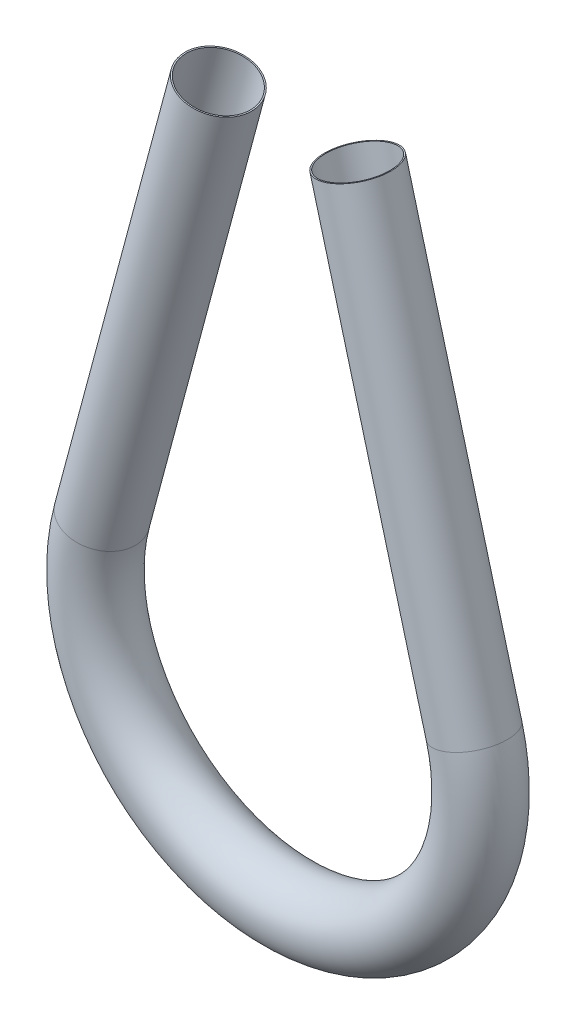
from build123d import *

# Parameters (mm, degrees)
SKETCH2_R   = 6.604
SKETCH2_R_2 = 6.35


with BuildPart() as part:
    # Sweep1: sweep along a path in Sketch1
    with BuildLine(Plane.XY) as sweep1_path:
        Line((-137.341657843, -9.296288517), (-159.618955177, -92.436294023))
        ThreePointArc((-159.618955177, -92.436294023), (-124.004465969, -138.85), (-88.389976761, -92.436294023))
        Line((-88.389976761, -92.436294023), (-110.667274096, -9.296288517))
    # Sketch2 → Sweep1 (sweep)
    with BuildSketch(Plane(origin=(-110.667274096, -9.296288517, 0), x_dir=(-0.965925826, -0.258819045, 0), z_dir=(0.258819045, -0.965925826, 0))):
        Circle(SKETCH2_R)
        Circle(SKETCH2_R_2, mode=Mode.SUBTRACT)
    sweep(path=sweep1_path.line)


solid = part.part
